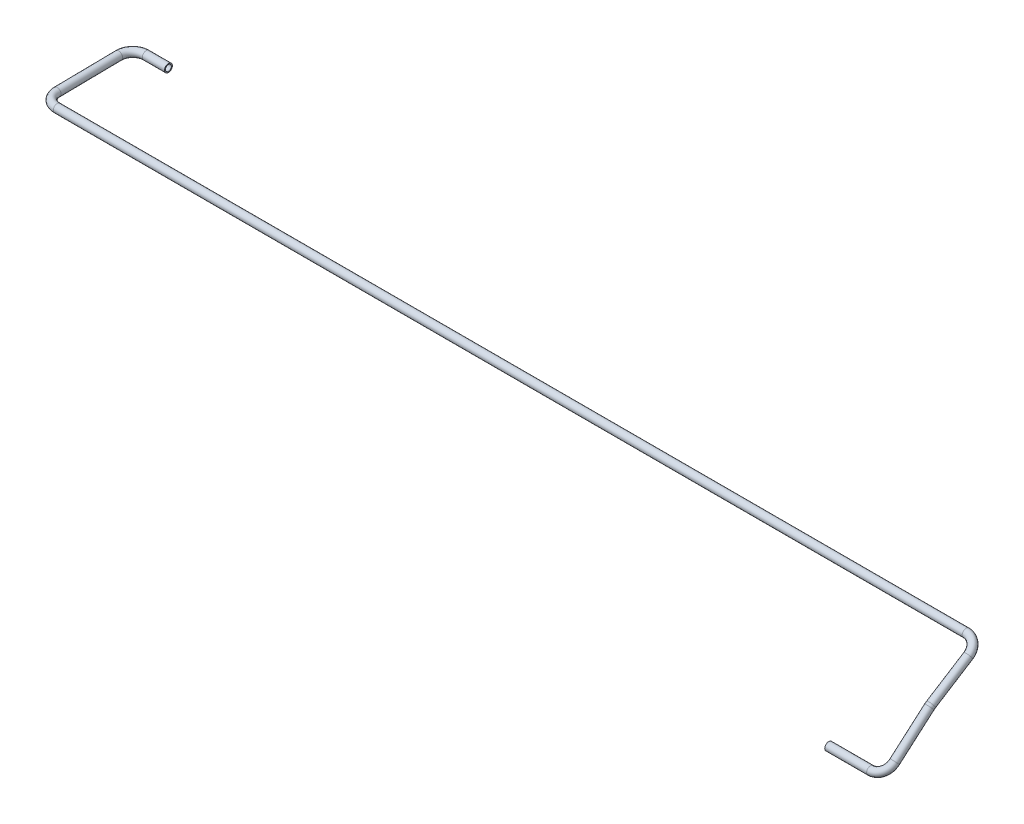
from build123d import *

# Parameters (mm, degrees)
SKETCH1_R   = 6
SKETCH1_R_2 = 4.5


with BuildPart() as part:
    # Sweep1: sweep along a curve in space
    with BuildLine() as sweep1_path:
        Line((0, 0, 0), (64, 0, 0))
        ThreePointArc((64, 0, 0), (78.849242405, 4.040914151, -4.6371146), (85, 13.7965439, -15.832099558))
        Line((85, 13.7965439, -15.832099558), (85, 59.939118646, -68.782595167))
        ThreePointArc((85, 61.862286052, -71.365286248), (85, 60.950278, -70.037024842), (85, 59.939118646, -68.782595167))
        Line((85, 61.862286052, -71.365286248), (85, 97.786147181, -128.244733036))
        ThreePointArc((64, 109, -146), (78.849242405, 105.715538552, -140.799602708), (85, 97.786147181, -128.244733036))
        Line((64, 109, -146), (-1325, 109, -146))
        ThreePointArc((-1325, 109, -146), (-1339.849242405, 109.090442538, -152.150092612), (-1346, 109.308790141, -166.997729607))
        Line((-1346, 109.308790141, -166.997729607), (-1346, 110.691209859, -261.002270393))
        ThreePointArc((-1325, 111, -282), (-1339.849242405, 110.909557462, -275.849907388), (-1346, 110.691209859, -261.002270393))
        Line((-1325, 111, -282), (-1291, 111, -282))
    # Sketch1 → Sweep1 (sweep)
    with BuildSketch(Plane(origin=(0, 0, 0), x_dir=(0, 0, -1), z_dir=(1, 0, 0))):
        Circle(SKETCH1_R)
        Circle(SKETCH1_R_2, mode=Mode.SUBTRACT)
    sweep(path=sweep1_path.line)


solid = part.part
